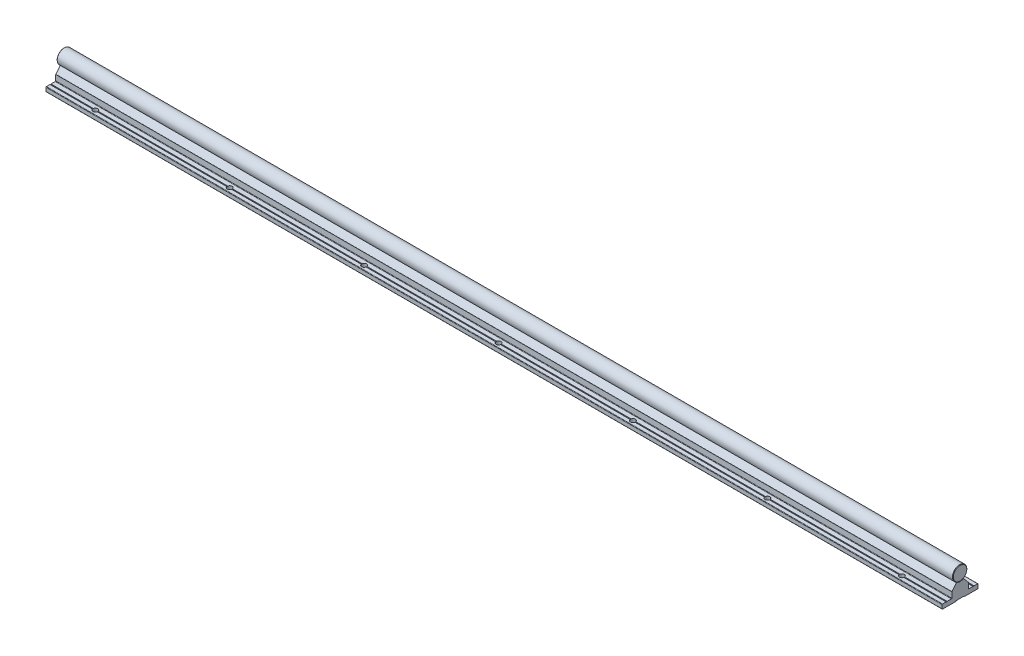
from build123d import *

# Parameters (mm, degrees)
EXTRUDE_4894_DEPTH       = 1500
SKETCH_1_3_R             = 8
EXTRUDE_5023_DEPTH       = 1500
FILLET_4_R               = 0.2
SKETCH_2_R               = 2.75
CUT_EXTRUDE_1_DEPTH      = 6
PATTERN_LINEAR_1_COUNT   = 20
PATTERN_LINEAR_1_PITCH   = 150
PATTERN_LINEAR_2_COUNT   = 20
PATTERN_LINEAR_2_PITCH   = 150
FILLET_1_R               = 0.3
CUT_EXTRUDE_2_DEPTH      = 3
FILLET_2_R               = 0.3
PATTERN_LINEAR_3_COUNT   = 20
PATTERN_LINEAR_3_PITCH   = 150
CHAMFER_1_SIZE           = 0.5
FILLET_3_R               = 0.5
FILLET_5_R               = 0.2
FILLET_6_R               = 0.1
FILLET_7_R               = 0.1
SKETCH_7_W               = 3500
SKETCH_7_H               = 1500
SKETCH_7_W_2             = 1000
SKETCH_7_H_2             = 1000
CUT_EXTRUDE_3_DEPTH      = 9.0000001
CUT_EXTRUDE_3_DEPTH_BACK = 26.0000001
CHAMFER_2_SIZE           = 0.5


with BuildPart() as part:
    # Sketch 1 → Extrude 4894 (new body, symmetric)
    with BuildSketch(Plane(origin=(0, 0, 0), x_dir=(0, 0, -1), z_dir=(1, 0, 0))):
        Polygon((-20, -25), (-4.75, -25), (-4.75, -24.4), (4.75, -24.4), (4.75, -25), (20, -25), (20, -20), (15.5, -20), (15, -20.5), (14.5, -20), (9.25, -20), (9.25, -13.3), (9.110116754, -13.3), (4, -7.21), (3.8, -7.21), (2.309327639, -7.659439004), (0, -8.355703281), (-2.309327657, -7.659438999), (-3.8, -7.21), (-4, -7.21), (-9.110116754, -13.3), (-9.25, -13.3), (-9.25, -20), (-14.5, -20), (-15, -20.5), (-15.5, -20), (-20, -20), align=None)
    extrude(amount=EXTRUDE_4894_DEPTH, both=True)

    # Fillet 4
    fillet_4_edges = [part.edges().sort_by_distance(p)[0] for p in [
        (0, -20, -15.5),
        (0, -24.4, -4.75),
        (0, -24.4, 4.75),
        (0, -20, 15.5),
        (0, -20, 14.5),
        (0, -8.355703281, 0),
        (0, -20, -14.5),
    ]]
    fillet(fillet_4_edges, radius=FILLET_4_R)

    # Sketch 2 → Cut-Extrude 1 (cut, through all)
    with BuildSketch(Plane(origin=(0, -20, 0), x_dir=(1, 0, 0), z_dir=(0, 1, 0))):
        with Locations((-1425, -15)):
            Circle(SKETCH_2_R)
        with Locations((-1425, 15)):
            Circle(SKETCH_2_R)
        with Locations((-1275, -15)):
            Circle(SKETCH_2_R)
        with Locations((-1275, 15)):
            Circle(SKETCH_2_R)
        with Locations((-1125, -15)):
            Circle(SKETCH_2_R)
        with Locations((-1125, 15)):
            Circle(SKETCH_2_R)
        with Locations((-975, -15)):
            Circle(SKETCH_2_R)
        with Locations((-975, 15)):
            Circle(SKETCH_2_R)
        with Locations((-825, -15)):
            Circle(SKETCH_2_R)
        with Locations((-825, 15)):
            Circle(SKETCH_2_R)
        with Locations((-675, -15)):
            Circle(SKETCH_2_R)
        with Locations((-675, 15)):
            Circle(SKETCH_2_R)
        with Locations((-525, -15)):
            Circle(SKETCH_2_R)
        with Locations((-525, 15)):
            Circle(SKETCH_2_R)
        with Locations((-375, -15)):
            Circle(SKETCH_2_R)
        with Locations((-375, 15)):
            Circle(SKETCH_2_R)
        with Locations((-225, -15)):
            Circle(SKETCH_2_R)
        with Locations((-225, 15)):
            Circle(SKETCH_2_R)
        with Locations((-75, -15)):
            Circle(SKETCH_2_R)
        with Locations((-75, 15)):
            Circle(SKETCH_2_R)
        with Locations((75, -15)):
            Circle(SKETCH_2_R)
        with Locations((75, 15)):
            Circle(SKETCH_2_R)
        with Locations((225, -15)):
            Circle(SKETCH_2_R)
        with Locations((225, 15)):
            Circle(SKETCH_2_R)
        with Locations((375, -15)):
            Circle(SKETCH_2_R)
        with Locations((375, 15)):
            Circle(SKETCH_2_R)
        with Locations((525, -15)):
            Circle(SKETCH_2_R)
        with Locations((525, 15)):
            Circle(SKETCH_2_R)
        with Locations((675, -15)):
            Circle(SKETCH_2_R)
        with Locations((675, 15)):
            Circle(SKETCH_2_R)
        with Locations((825, -15)):
            Circle(SKETCH_2_R)
        with Locations((825, 15)):
            Circle(SKETCH_2_R)
        with Locations((975, -15)):
            Circle(SKETCH_2_R)
        with Locations((975, 15)):
            Circle(SKETCH_2_R)
        with Locations((1125, -15)):
            Circle(SKETCH_2_R)
        with Locations((1125, 15)):
            Circle(SKETCH_2_R)
        with Locations((1275, -15)):
            Circle(SKETCH_2_R)
        with Locations((1275, 15)):
            Circle(SKETCH_2_R)
        with Locations((1425, -15)):
            Circle(SKETCH_2_R)
        with Locations((1425, 15)):
            Circle(SKETCH_2_R)
    extrude(amount=-CUT_EXTRUDE_1_DEPTH, mode=Mode.SUBTRACT)

    # Sketch 3 → Cut-Revolve 1 (revolve, cut)
    with BuildSketch(Plane.XY):
        Polygon((-1425, 0), (-1427.2, -1.270170592), (-1427.2, -7.5), (-1427.75, -7.5), (-1427.75, -19), (-1429.75, -19), (-1429.75, -24.4), (-1425, -24.4), align=None)
    cut_revolve_1 = revolve(axis=Axis((-1425, 56.434869358, 0), (0, -1, 0)), mode=Mode.SUBTRACT)

    # Pattern Linear 1: Cut-Revolve 1 ×20
    with Locations(*[(i * PATTERN_LINEAR_1_PITCH, 0, 0) for i in range(1, PATTERN_LINEAR_1_COUNT)]):
        add(cut_revolve_1, mode=Mode.SUBTRACT)

    # Fillet 3
    fillet_3_edges = [part.edges().sort_by_distance(p)[0] for p in [
        (0, -20, -9.25),
        (0, -20, -20),
        (0, -25, -20),
        (0, -25, -4.75),
        (0, -25, 4.75),
        (0, -20, 9.25),
        (0, -25, 20),
        (0, -20, 20),
    ]]
    fillet(fillet_3_edges, radius=FILLET_3_R)

    # Fillet 5
    fillet_5_edges = [part.edges().sort_by_distance(p)[0] for p in [
        (0, -7.21, 4),
        (0, -7.21, 3.8),
        (0, -7.21, -3.8),
        (0, -7.21, -4),
    ]]
    fillet(fillet_5_edges, radius=FILLET_5_R)

    # Fillet 6
    fillet_6_edges = [part.edges().sort_by_distance(p)[0] for p in [
        (0, -13.3, 9.25),
        (0, -13.3, -9.25),
    ]]
    fillet(fillet_6_edges, radius=FILLET_6_R)

    # Fillet 7
    fillet_7_edges = [part.edges().sort_by_distance(p)[0] for p in [
        (0, -13.3, 9.110116754),
        (0, -13.3, -9.110116754),
    ]]
    fillet(fillet_7_edges, radius=FILLET_7_R)


with BuildPart() as body_2:
    # Sketch 1_3 → Extrude 5023 (new body, symmetric)
    with BuildSketch(Plane(origin=(0, 0, 0), x_dir=(0, 0, -1), z_dir=(1, 0, 0))):
        Circle(SKETCH_1_3_R)
    extrude(amount=EXTRUDE_5023_DEPTH, both=True)

    # Sketch 4 → Cut-Revolve 2 (revolve, cut)
    with BuildSketch(Plane.XY):
        Polygon((-1425, -10), (-1427.2, -10), (-1427.2, -1.270170592), (-1425, 0), align=None)
    cut_revolve_2 = revolve(axis=Axis((-1425, 39.840222878, 0), (0, -1, 0)), mode=Mode.SUBTRACT)

    # Pattern Linear 2: Cut-Revolve 2 ×20
    with Locations(*[(i * PATTERN_LINEAR_2_PITCH, 0, 0) for i in range(1, PATTERN_LINEAR_2_COUNT)]):
        add(cut_revolve_2, mode=Mode.SUBTRACT)

    # Chamfer 1
    chamfer_1_edges = [body_2.edges().sort_by_distance(p)[0] for p in [
        (-1500, 0, 8),
        (1500, 0, 8),
    ]]
    chamfer(chamfer_1_edges, length=CHAMFER_1_SIZE)


with BuildPart() as body_3:
    # Sketch 5 → Revolve 1 (revolve)
    with BuildSketch(Plane.XY):
        Polygon((-1425, -24), (-1429.5, -24), (-1429.5, -19), (-1427.5, -19), (-1427.5, -2.461880215), (-1426.7, -2), (-1425, -2), align=None)
    revolve(axis=Axis((-1425, 35.529626596, 0), (0, -1, 0)))

    # Fillet 1
    fillet_1_edges = [body_3.edges().sort_by_distance(p)[0] for p in [
        (-1420.5, -19, 0),
    ]]
    fillet(fillet_1_edges, radius=FILLET_1_R)

    # Sketch 6 → Cut-Extrude 2 (cut)
    with BuildSketch(Plane.XZ.offset(24)):
        Polygon((-1423.25, -1.010362971), (-1423.25, 1.010362971), (-1425, 2.020725942), (-1426.75, 1.010362971), (-1426.75, -1.010362971), (-1425, -2.020725942), align=None)
    extrude(amount=-CUT_EXTRUDE_2_DEPTH, mode=Mode.SUBTRACT)

    # Fillet 2
    fillet_2_edges = [body_3.edges().sort_by_distance(p)[0] for p in [
        (-1424.125, -24, -1.515544457),
        (-1423.25, -24, 0),
        (-1424.125, -24, 1.515544457),
        (-1425.875, -24, 1.515544457),
        (-1426.75, -24, 0),
        (-1425.875, -24, -1.515544457),
        (-1420.5, -24, 0),
    ]]
    fillet(fillet_2_edges, radius=FILLET_2_R)


with BuildPart() as pattern_linear_3_1:
    # Pattern Linear 3: pattern copy
    add(body_3.part.moved(Location(Vector(1, 0, 0) * (1 * PATTERN_LINEAR_3_PITCH))))


with BuildPart() as pattern_linear_3_2:
    # Pattern Linear 3: pattern copy
    add(body_3.part.moved(Location(Vector(1, 0, 0) * (2 * PATTERN_LINEAR_3_PITCH))))


with BuildPart() as pattern_linear_3_3:
    # Pattern Linear 3: pattern copy
    add(body_3.part.moved(Location(Vector(1, 0, 0) * (3 * PATTERN_LINEAR_3_PITCH))))


with BuildPart() as pattern_linear_3_4:
    # Pattern Linear 3: pattern copy
    add(body_3.part.moved(Location(Vector(1, 0, 0) * (4 * PATTERN_LINEAR_3_PITCH))))


with BuildPart() as pattern_linear_3_5:
    # Pattern Linear 3: pattern copy
    add(body_3.part.moved(Location(Vector(1, 0, 0) * (5 * PATTERN_LINEAR_3_PITCH))))


with BuildPart() as pattern_linear_3_6:
    # Pattern Linear 3: pattern copy
    add(body_3.part.moved(Location(Vector(1, 0, 0) * (6 * PATTERN_LINEAR_3_PITCH))))


with BuildPart() as pattern_linear_3_7:
    # Pattern Linear 3: pattern copy
    add(body_3.part.moved(Location(Vector(1, 0, 0) * (7 * PATTERN_LINEAR_3_PITCH))))


with BuildPart() as pattern_linear_3_8:
    # Pattern Linear 3: pattern copy
    add(body_3.part.moved(Location(Vector(1, 0, 0) * (8 * PATTERN_LINEAR_3_PITCH))))


with BuildPart() as pattern_linear_3_9:
    # Pattern Linear 3: pattern copy
    add(body_3.part.moved(Location(Vector(1, 0, 0) * (9 * PATTERN_LINEAR_3_PITCH))))


with BuildPart() as pattern_linear_3_10:
    # Pattern Linear 3: pattern copy
    add(body_3.part.moved(Location(Vector(1, 0, 0) * (10 * PATTERN_LINEAR_3_PITCH))))


with BuildPart() as pattern_linear_3_11:
    # Pattern Linear 3: pattern copy
    add(body_3.part.moved(Location(Vector(1, 0, 0) * (11 * PATTERN_LINEAR_3_PITCH))))


with BuildPart() as pattern_linear_3_12:
    # Pattern Linear 3: pattern copy
    add(body_3.part.moved(Location(Vector(1, 0, 0) * (12 * PATTERN_LINEAR_3_PITCH))))


with BuildPart() as pattern_linear_3_13:
    # Pattern Linear 3: pattern copy
    add(body_3.part.moved(Location(Vector(1, 0, 0) * (13 * PATTERN_LINEAR_3_PITCH))))


with BuildPart() as pattern_linear_3_14:
    # Pattern Linear 3: pattern copy
    add(body_3.part.moved(Location(Vector(1, 0, 0) * (14 * PATTERN_LINEAR_3_PITCH))))


with BuildPart() as pattern_linear_3_15:
    # Pattern Linear 3: pattern copy
    add(body_3.part.moved(Location(Vector(1, 0, 0) * (15 * PATTERN_LINEAR_3_PITCH))))


with BuildPart() as pattern_linear_3_16:
    # Pattern Linear 3: pattern copy
    add(body_3.part.moved(Location(Vector(1, 0, 0) * (16 * PATTERN_LINEAR_3_PITCH))))


with BuildPart() as pattern_linear_3_17:
    # Pattern Linear 3: pattern copy
    add(body_3.part.moved(Location(Vector(1, 0, 0) * (17 * PATTERN_LINEAR_3_PITCH))))


with BuildPart() as pattern_linear_3_18:
    # Pattern Linear 3: pattern copy
    add(body_3.part.moved(Location(Vector(1, 0, 0) * (18 * PATTERN_LINEAR_3_PITCH))))


with BuildPart() as pattern_linear_3_19:
    # Pattern Linear 3: pattern copy
    add(body_3.part.moved(Location(Vector(1, 0, 0) * (19 * PATTERN_LINEAR_3_PITCH))))


with BuildPart() as cut_extrude_3_tool:
    # Sketch 7 → Cut-Extrude 3 (new body, two sides)
    with BuildSketch(Plane(origin=(0, 0, 0), x_dir=(1, 0, 0), z_dir=(0, 1, 0))) as cut_extrude_3_sk:
        Rectangle(SKETCH_7_W, SKETCH_7_H)
        with Locations((-75, 0)):
            Rectangle(SKETCH_7_W_2, SKETCH_7_H_2, mode=Mode.SUBTRACT)
    extrude(amount=CUT_EXTRUDE_3_DEPTH)
    extrude(cut_extrude_3_sk.sketch, amount=-CUT_EXTRUDE_3_DEPTH_BACK)


with BuildPart() as part_1:
    add(part.part)

    # Cut-Extrude 3: cut by cut_extrude_3_tool
    add(cut_extrude_3_tool.part, mode=Mode.SUBTRACT)


with BuildPart() as body_2_1:
    add(body_2.part)

    # Cut-Extrude 3: cut by cut_extrude_3_tool
    add(cut_extrude_3_tool.part, mode=Mode.SUBTRACT)

    # Chamfer 2
    chamfer_2_edges = [body_2_1.edges().sort_by_distance(p)[0] for p in [
        (-575, 0, 8),
        (425, 0, 8),
    ]]
    chamfer(chamfer_2_edges, length=CHAMFER_2_SIZE)


with BuildPart() as body_3_1:
    add(body_3.part)

    # Cut-Extrude 3: cut by cut_extrude_3_tool
    add(cut_extrude_3_tool.part, mode=Mode.SUBTRACT)


with BuildPart() as pattern_linear_3_1_1:
    add(pattern_linear_3_1.part)

    # Cut-Extrude 3: cut by cut_extrude_3_tool
    add(cut_extrude_3_tool.part, mode=Mode.SUBTRACT)


with BuildPart() as pattern_linear_3_2_1:
    add(pattern_linear_3_2.part)

    # Cut-Extrude 3: cut by cut_extrude_3_tool
    add(cut_extrude_3_tool.part, mode=Mode.SUBTRACT)


with BuildPart() as pattern_linear_3_3_1:
    add(pattern_linear_3_3.part)

    # Cut-Extrude 3: cut by cut_extrude_3_tool
    add(cut_extrude_3_tool.part, mode=Mode.SUBTRACT)


with BuildPart() as pattern_linear_3_4_1:
    add(pattern_linear_3_4.part)

    # Cut-Extrude 3: cut by cut_extrude_3_tool
    add(cut_extrude_3_tool.part, mode=Mode.SUBTRACT)


with BuildPart() as pattern_linear_3_5_1:
    add(pattern_linear_3_5.part)

    # Cut-Extrude 3: cut by cut_extrude_3_tool
    add(cut_extrude_3_tool.part, mode=Mode.SUBTRACT)


with BuildPart() as pattern_linear_3_13_1:
    add(pattern_linear_3_13.part)

    # Cut-Extrude 3: cut by cut_extrude_3_tool
    add(cut_extrude_3_tool.part, mode=Mode.SUBTRACT)


with BuildPart() as pattern_linear_3_14_1:
    add(pattern_linear_3_14.part)

    # Cut-Extrude 3: cut by cut_extrude_3_tool
    add(cut_extrude_3_tool.part, mode=Mode.SUBTRACT)


with BuildPart() as pattern_linear_3_15_1:
    add(pattern_linear_3_15.part)

    # Cut-Extrude 3: cut by cut_extrude_3_tool
    add(cut_extrude_3_tool.part, mode=Mode.SUBTRACT)


with BuildPart() as pattern_linear_3_16_1:
    add(pattern_linear_3_16.part)

    # Cut-Extrude 3: cut by cut_extrude_3_tool
    add(cut_extrude_3_tool.part, mode=Mode.SUBTRACT)


with BuildPart() as pattern_linear_3_17_1:
    add(pattern_linear_3_17.part)

    # Cut-Extrude 3: cut by cut_extrude_3_tool
    add(cut_extrude_3_tool.part, mode=Mode.SUBTRACT)


with BuildPart() as pattern_linear_3_18_1:
    add(pattern_linear_3_18.part)

    # Cut-Extrude 3: cut by cut_extrude_3_tool
    add(cut_extrude_3_tool.part, mode=Mode.SUBTRACT)


with BuildPart() as pattern_linear_3_19_1:
    add(pattern_linear_3_19.part)

    # Cut-Extrude 3: cut by cut_extrude_3_tool
    add(cut_extrude_3_tool.part, mode=Mode.SUBTRACT)


solid = Compound([pattern_linear_3_6.part, pattern_linear_3_7.part, pattern_linear_3_8.part, pattern_linear_3_9.part, pattern_linear_3_10.part, pattern_linear_3_11.part, pattern_linear_3_12.part, part_1.part, body_2_1.part])
